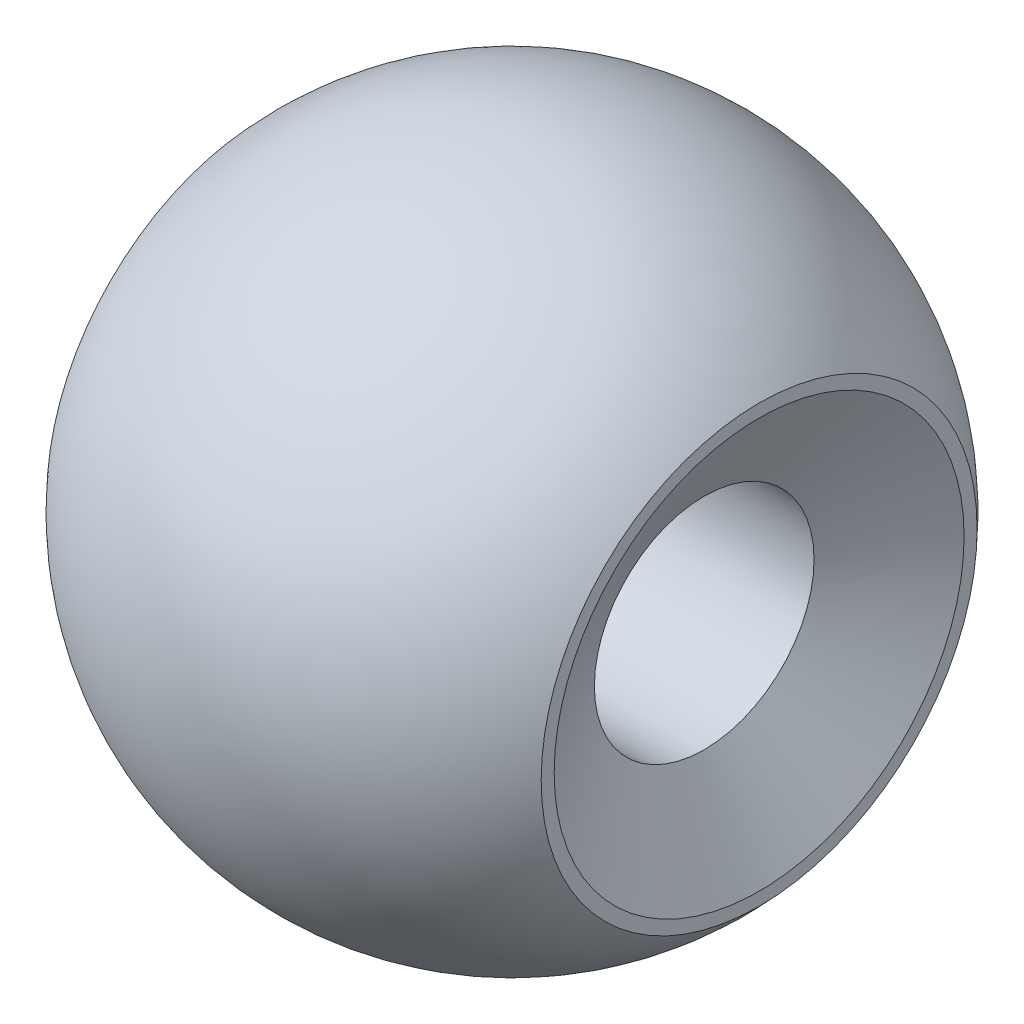
from build123d import *

# Parameters (mm, degrees)
CUT_EXTRUDE1_DEPTH = 10
CUT_EXTRUDE2_REACH = 11
SKETCH4_R          = 2
CHAMFER1_SIZE      = 1
CHAMFER1_SIZE2     = 1.732050808


with BuildPart() as part:
    # Sketch2 → Revolve10 (revolve)
    with BuildSketch(Plane(origin=(0, 0, 0), x_dir=(1, 0, 0), z_dir=(0, 1, 0))):
        with BuildLine():
            Line((0, 6), (0, -6))
            ThreePointArc((0, -6), (-6, 0), (0, 6))
        make_face()
    revolve(axis=Axis((0, 0, -6), (0, 0, 1)))

    # Sketch3 → Cut-Extrude1 (cut, symmetric)
    with BuildSketch(Plane(origin=(0, 0, 0), x_dir=(1, 0, 0), z_dir=(0, 1, 0))):
        Polygon((-4.5, 6.116617365), (-8.039926199, -0.619090826), (-4.5, -6.116617365), align=None)
        Polygon((4.5, -6.116617365), (4.5, 6.116617365), (7.115417232, -1.229927109), align=None)
    extrude(amount=CUT_EXTRUDE1_DEPTH, both=True, mode=Mode.SUBTRACT)

    # Sketch4 → Cut-Extrude2 (cut, up to next)
    with BuildSketch(Plane(origin=(4.5, 0, 0), x_dir=(0, 0, -1), z_dir=(1, 0, 0)), mode=Mode.PRIVATE) as cut_extrude2_sk1:
        Circle(SKETCH4_R)
    cut_extrude2_tool1 = extrude(cut_extrude2_sk1.sketch, amount=-CUT_EXTRUDE2_REACH, mode=Mode.PRIVATE) & part.part
    add(cut_extrude2_tool1.solids().sort_by_distance((4.5, 0, 0))[0], mode=Mode.SUBTRACT)

    # Chamfer1
    chamfer1_edges = [part.edges().sort_by_distance(p)[0] for p in [
        (4.5, 0, 2),
    ]]
    chamfer1_side = [part.faces().sort_by_distance(p)[0] for p in [
        (0, 0, 2),
    ]]
    chamfer(chamfer1_edges, length=CHAMFER1_SIZE, length2=CHAMFER1_SIZE2, reference=chamfer1_side[0])


solid = part.part
